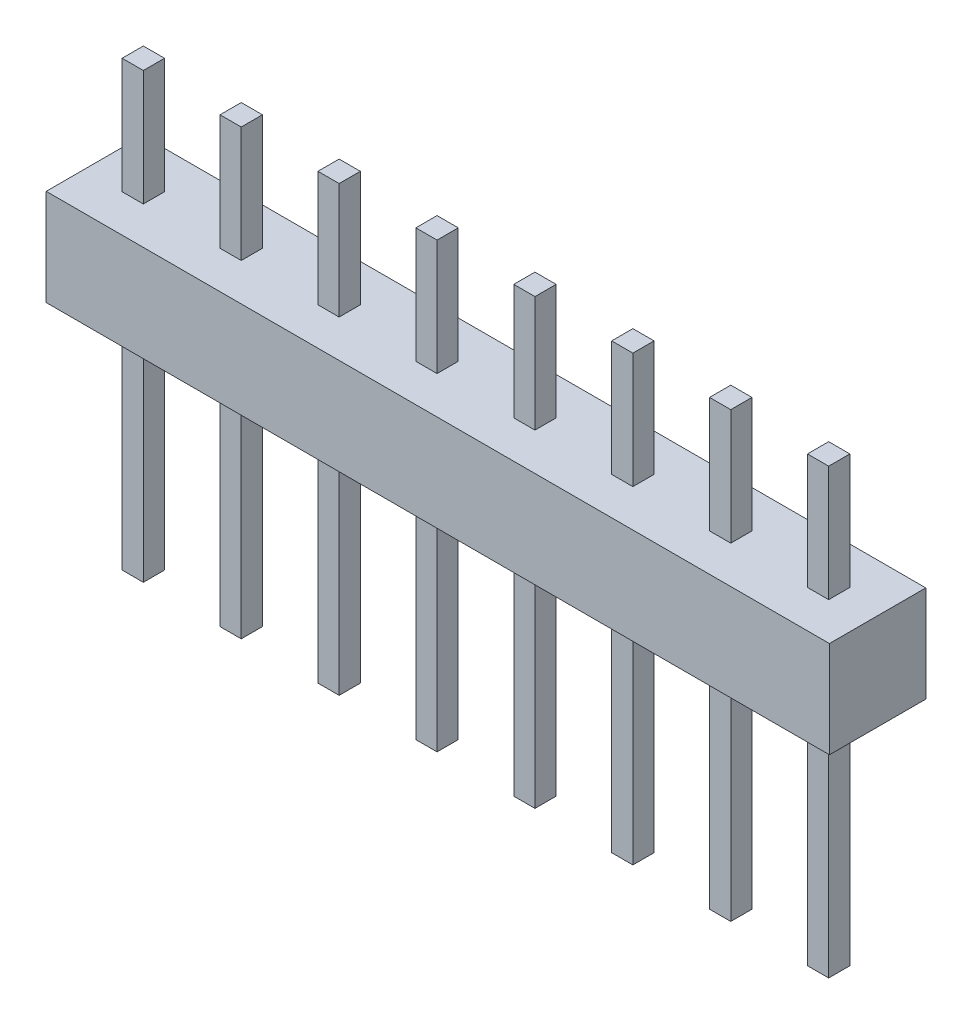
from build123d import *

# Parameters (mm, degrees)
SKETCH1_W             = 20.32
SKETCH1_H             = 2.5
BOSS_EXTRUDE1_DEPTH   = 1.25
SKETCH2_W             = 0.55
SKETCH2_H             = 0.55
BOSS_EXTRUDE2_DEPTH   = 6
BOSS_EXTRUDE2_2_DEPTH = 6
BOSS_EXTRUDE2_3_DEPTH = 6
BOSS_EXTRUDE2_4_DEPTH = 6
BOSS_EXTRUDE2_5_DEPTH = 6
BOSS_EXTRUDE2_6_DEPTH = 6
BOSS_EXTRUDE2_7_DEPTH = 6
BOSS_EXTRUDE2_8_DEPTH = 6
SKETCH2_2_W           = 0.55
SKETCH2_2_H           = 0.55
BOSS_EXTRUDE3_DEPTH   = 5.5
BOSS_EXTRUDE3_2_DEPTH = 5.5
BOSS_EXTRUDE3_3_DEPTH = 5.5
BOSS_EXTRUDE3_4_DEPTH = 5.5
BOSS_EXTRUDE3_5_DEPTH = 5.5
BOSS_EXTRUDE3_6_DEPTH = 5.5
BOSS_EXTRUDE3_7_DEPTH = 5.5
BOSS_EXTRUDE3_8_DEPTH = 5.5


with BuildPart() as part:
    # Sketch1 → Boss-Extrude1 (new, symmetric)
    with BuildSketch(Plane.XY):
        with Locations((10.16, 1.25)):
            Rectangle(SKETCH1_W, SKETCH1_H)
    extrude(amount=BOSS_EXTRUDE1_DEPTH, both=True)


with BuildPart() as body_2:
    # Sketch2 → Boss-Extrude2 (new body)
    with BuildSketch(Plane.XZ):
        with Locations((3.81, 0)):
            Rectangle(SKETCH2_W, SKETCH2_H)
    extrude(amount=BOSS_EXTRUDE2_DEPTH)


with BuildPart() as body_3:
    # Sketch2 → Boss-Extrude2 2 (new body)
    with BuildSketch(Plane.XZ):
        with Locations((1.27, 0)):
            Rectangle(SKETCH2_W, SKETCH2_H)
    extrude(amount=BOSS_EXTRUDE2_2_DEPTH)


with BuildPart() as body_4:
    # Sketch2 → Boss-Extrude2 3 (new body)
    with BuildSketch(Plane.XZ):
        with Locations((6.35, 0)):
            Rectangle(SKETCH2_W, SKETCH2_H)
    extrude(amount=BOSS_EXTRUDE2_3_DEPTH)


with BuildPart() as body_5:
    # Sketch2 → Boss-Extrude2 4 (new body)
    with BuildSketch(Plane.XZ):
        with Locations((8.89, 0)):
            Rectangle(SKETCH2_W, SKETCH2_H)
    extrude(amount=BOSS_EXTRUDE2_4_DEPTH)


with BuildPart() as body_6:
    # Sketch2 → Boss-Extrude2 5 (new body)
    with BuildSketch(Plane.XZ):
        with Locations((11.43, 0)):
            Rectangle(SKETCH2_W, SKETCH2_H)
    extrude(amount=BOSS_EXTRUDE2_5_DEPTH)


with BuildPart() as body_7:
    # Sketch2 → Boss-Extrude2 6 (new body)
    with BuildSketch(Plane.XZ):
        with Locations((13.97, 0)):
            Rectangle(SKETCH2_W, SKETCH2_H)
    extrude(amount=BOSS_EXTRUDE2_6_DEPTH)


with BuildPart() as body_8:
    # Sketch2 → Boss-Extrude2 7 (new body)
    with BuildSketch(Plane.XZ):
        with Locations((16.51, 0)):
            Rectangle(SKETCH2_W, SKETCH2_H)
    extrude(amount=BOSS_EXTRUDE2_7_DEPTH)


with BuildPart() as body_9:
    # Sketch2 → Boss-Extrude2 8 (new body)
    with BuildSketch(Plane.XZ):
        with Locations((19.05, 0)):
            Rectangle(SKETCH2_W, SKETCH2_H)
    extrude(amount=BOSS_EXTRUDE2_8_DEPTH)


with BuildPart() as body_10:
    # Sketch2_2 → Boss-Extrude3 (new body)
    with BuildSketch(Plane.XZ):
        with Locations((3.81, 0)):
            Rectangle(SKETCH2_2_W, SKETCH2_2_H)
    extrude(amount=-BOSS_EXTRUDE3_DEPTH)


with BuildPart() as body_11:
    # Sketch2_2 → Boss-Extrude3 2 (new body)
    with BuildSketch(Plane.XZ):
        with Locations((1.27, 0)):
            Rectangle(SKETCH2_2_W, SKETCH2_2_H)
    extrude(amount=-BOSS_EXTRUDE3_2_DEPTH)


with BuildPart() as body_12:
    # Sketch2_2 → Boss-Extrude3 3 (new body)
    with BuildSketch(Plane.XZ):
        with Locations((6.35, 0)):
            Rectangle(SKETCH2_2_W, SKETCH2_2_H)
    extrude(amount=-BOSS_EXTRUDE3_3_DEPTH)


with BuildPart() as body_13:
    # Sketch2_2 → Boss-Extrude3 4 (new body)
    with BuildSketch(Plane.XZ):
        with Locations((8.89, 0)):
            Rectangle(SKETCH2_2_W, SKETCH2_2_H)
    extrude(amount=-BOSS_EXTRUDE3_4_DEPTH)


with BuildPart() as body_14:
    # Sketch2_2 → Boss-Extrude3 5 (new body)
    with BuildSketch(Plane.XZ):
        with Locations((11.43, 0)):
            Rectangle(SKETCH2_2_W, SKETCH2_2_H)
    extrude(amount=-BOSS_EXTRUDE3_5_DEPTH)


with BuildPart() as body_15:
    # Sketch2_2 → Boss-Extrude3 6 (new body)
    with BuildSketch(Plane.XZ):
        with Locations((13.97, 0)):
            Rectangle(SKETCH2_2_W, SKETCH2_2_H)
    extrude(amount=-BOSS_EXTRUDE3_6_DEPTH)


with BuildPart() as body_16:
    # Sketch2_2 → Boss-Extrude3 7 (new body)
    with BuildSketch(Plane.XZ):
        with Locations((16.51, 0)):
            Rectangle(SKETCH2_2_W, SKETCH2_2_H)
    extrude(amount=-BOSS_EXTRUDE3_7_DEPTH)


with BuildPart() as body_17:
    # Sketch2_2 → Boss-Extrude3 8 (new body)
    with BuildSketch(Plane.XZ):
        with Locations((19.05, 0)):
            Rectangle(SKETCH2_2_W, SKETCH2_2_H)
    extrude(amount=-BOSS_EXTRUDE3_8_DEPTH)


solid = Compound([part.part, body_2.part, body_3.part, body_4.part, body_5.part, body_6.part, body_7.part, body_8.part, body_9.part, body_10.part, body_11.part, body_12.part, body_13.part, body_14.part, body_15.part, body_16.part, body_17.part])
